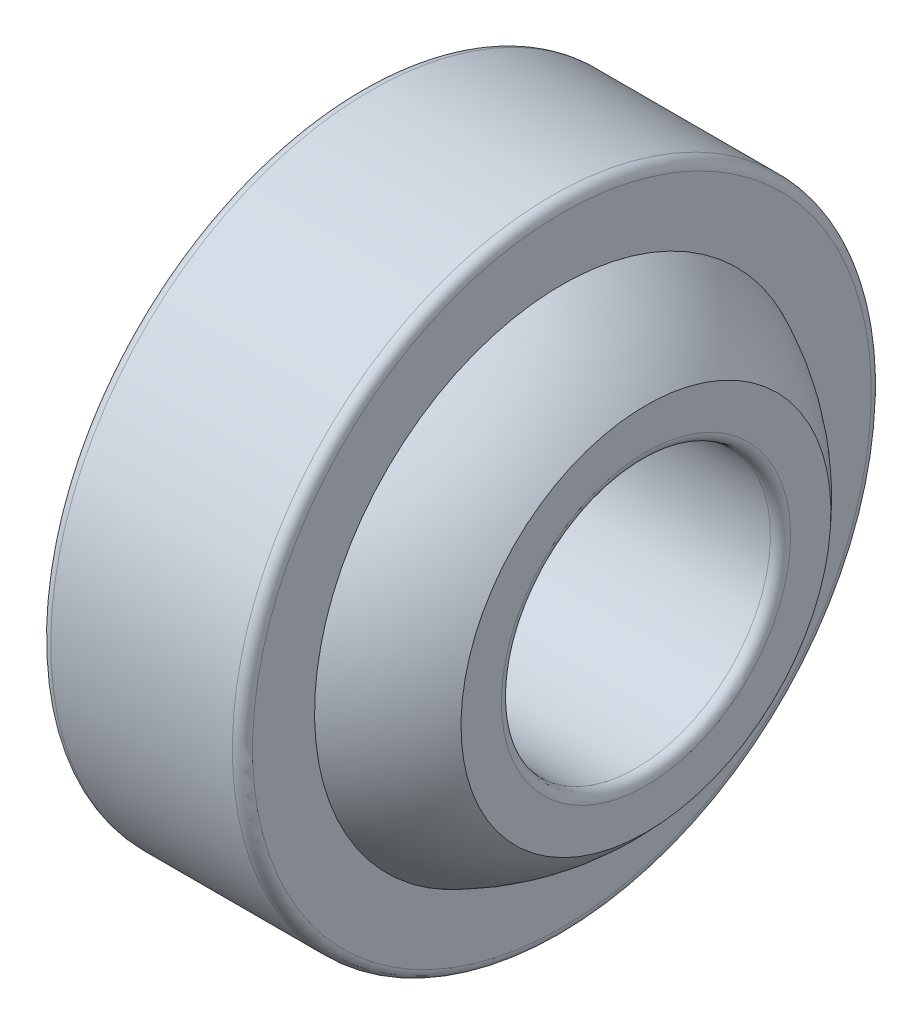
from build123d import *


with BuildPart() as part:
    # 草图2 → 旋转1 (revolve)
    with BuildSketch(Plane.XY):
        with BuildLine():
            Line((-3, 7.355073253), (-3, 9.2))
            ThreePointArc((-3, 9.2), (-2.912132034, 9.412132034), (-2.7, 9.5))
            Line((-2.7, 9.5), (2.7, 9.5))
            ThreePointArc((2.7, 9.5), (2.912132034, 9.412132034), (3, 9.2))
            Line((3, 9.2), (3, 7.355073253))
            ThreePointArc((3, 7.355073253), (0, 8), (-3, 7.355073253))
        make_face()
    revolve(axis=Axis((-7, 0, 0), (1, 0, 0)))


with BuildPart() as body_2:
    # 草图3 → 旋转2 (revolve)
    with BuildSketch(Plane.XY):
        with BuildLine():
            Line((-5.5, 5.5), (-5.5, 4.3))
            ThreePointArc((-5.5, 4.3), (-5.412132034, 4.087867966), (-5.2, 4))
            Line((-5.2, 4), (5.2, 4))
            ThreePointArc((5.2, 4), (5.412132034, 4.087867966), (5.5, 4.3))
            Line((5.5, 4.3), (5.5, 5.5))
            ThreePointArc((5.5, 5.5), (0, 8), (-5.5, 5.5))
        make_face()
    revolve(axis=Axis((-7, 0, 0), (1, 0, 0)))


solid = Compound([part.part, body_2.part])
